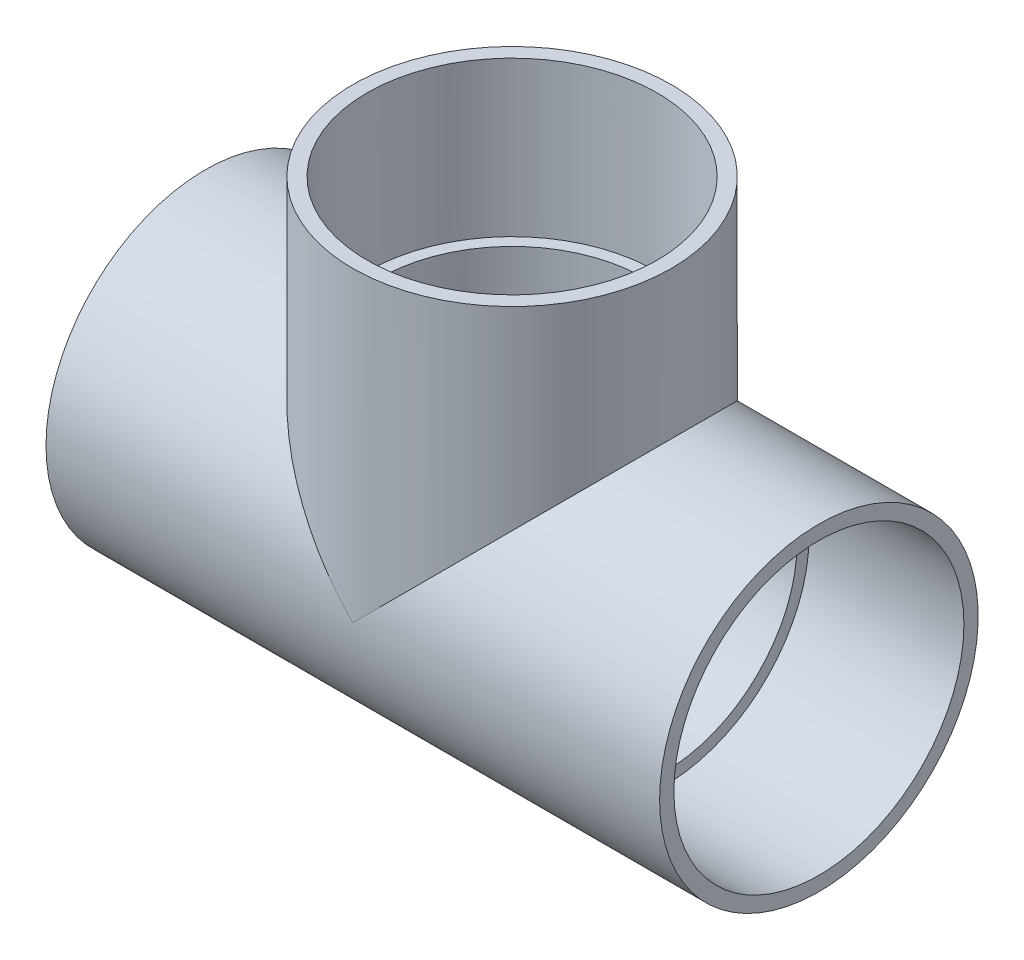
from build123d import *

# Parameters (mm, degrees)
SKETCH4_R           = 92.71
BOSS_EXTRUDE1_DEPTH = 177.8
SKETCH5_R           = 92.71
BOSS_EXTRUDE2_DEPTH = 88.9


with BuildPart() as part:
    # Sketch1 → Revolve1 (revolve)
    with BuildSketch(Plane.XY, mode=Mode.PRIVATE) as revolve1_sk:
        Polygon((-178.59375, -92.71), (-88.9, -92.71), (-88.9, -83.9978), (-178.59375, -84.4169), align=None)
        Polygon((178.59375, -84.4169), (88.9, -83.9978), (88.9, -92.71), (178.59375, -92.71), align=None)
    revolve(revolve1_sk.sketch.rotate(Axis((-178.59375, 0, 0), (1, 0, 0)), 270), axis=Axis((-178.59375, 0, 0), (1, 0, 0)))



with BuildPart() as body_2:
    # Sketch2 → Revolve2 (revolve)
    with BuildSketch(Plane.XY):
        Polygon((84.4169, 178.59375), (83.9978, 88.9), (92.71, 88.9), (92.71, 178.59375), align=None)
    revolve(axis=Axis((0, 0, 0), (0, 1, 0)))


with BuildPart() as part_1:
    add(part.part)

    add(body_2.part)  # Boss-Extrude1 merges body 2
    # Sketch4 → Boss-Extrude1 (add)
    with BuildSketch(Plane(origin=(-88.9, 0, 0), x_dir=(0, 0, -1), z_dir=(1, 0, 0))):
        with Locations(Location((0, 0, 0), (0, 0, 180))):
            Circle(SKETCH4_R)
    extrude(amount=BOSS_EXTRUDE1_DEPTH)

    # Sketch5 → Boss-Extrude2 (add)
    with BuildSketch(Plane.XZ.offset(-88.9)):
        Circle(SKETCH5_R)
    extrude(amount=BOSS_EXTRUDE2_DEPTH)

    # Sketch6 → Cut-Revolve1 (revolve, cut)
    with BuildSketch(Plane.XY, mode=Mode.PRIVATE) as cut_revolve1_sk:
        Polygon((-178.59375, -84.4169), (-88.9, -83.9978), (-88.9, -77.0255), (88.9, -77.0255), (88.9, -83.9978), (178.59375, -84.4169), (178.59375, 0), (-178.59375, 0), align=None)
    revolve(cut_revolve1_sk.sketch.rotate(Axis((178.59375, 0, 0), (-1, 0, 0)), 270), axis=Axis((178.59375, 0, 0), (-1, 0, 0)), mode=Mode.SUBTRACT)

    # Sketch7 → Cut-Revolve2 (revolve, cut)
    with BuildSketch(Plane.XY):
        Polygon((84.4169, 178.59375), (83.9978, 88.9), (77.0255, 88.9), (77.0255, 0), (0, 0), (0, 178.59375), align=None)
    revolve(axis=Axis((0, 0, 0), (0, 1, 0)), mode=Mode.SUBTRACT)


solid = part_1.part
